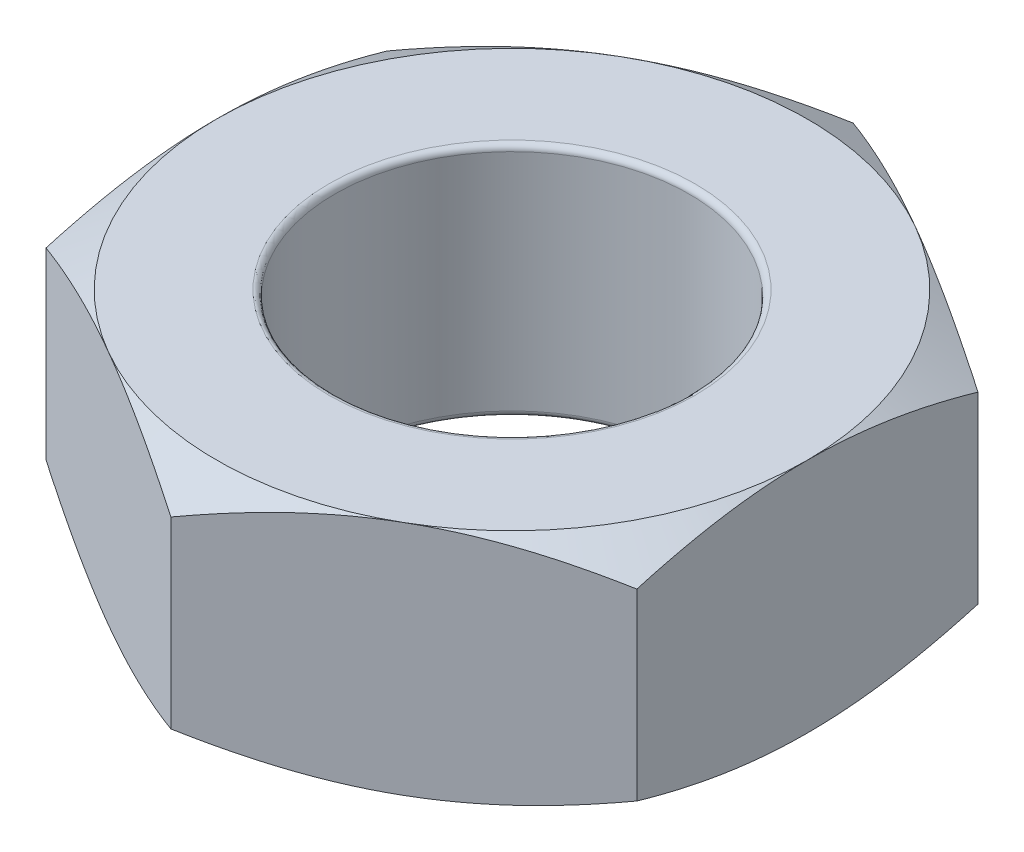
from build123d import *

# Parameters (mm, degrees)
SKETCH2_R           = 1.5
BOSS_EXTRUDE1_DEPTH = 2
SKETCH3_OUTSIDE_W   = 15.508
SKETCH3_OUTSIDE_H   = 16.282
SKETCH3_OUTSIDE_R   = 2.5
CUT_EXTRUDE1_DEPTH  = 2
CUT_EXTRUDE1_TAPER  = 60
SKETCH4_OUTSIDE_W   = 15.508
SKETCH4_OUTSIDE_H   = 16.282
SKETCH4_OUTSIDE_R   = 2.5
CUT_EXTRUDE2_DEPTH  = 2
CUT_EXTRUDE2_TAPER  = 60
FILLET1_R           = 0.05


with BuildPart() as part:
    # Sketch2 → Boss-Extrude1 (new body)
    with BuildSketch(Plane(origin=(0, 0, 0), x_dir=(1, 0, 0), z_dir=(0, 1, 0))):
        Polygon((2.5, -1.443375673), (2.5, 1.443375673), (0, 2.886751346), (-2.5, 1.443375673), (-2.5, -1.443375673), (0, -2.886751346), align=None)
        Circle(SKETCH2_R, mode=Mode.SUBTRACT)
    extrude(amount=BOSS_EXTRUDE1_DEPTH)

    # Sketch3 outside → Cut-Extrude1 (cut)
    with BuildSketch(Plane(origin=(0, 2, 0), x_dir=(1, 0, 0), z_dir=(0, 1, 0))):
        Rectangle(SKETCH3_OUTSIDE_W, SKETCH3_OUTSIDE_H)
        Circle(SKETCH3_OUTSIDE_R, mode=Mode.SUBTRACT)
    extrude(amount=-CUT_EXTRUDE1_DEPTH, taper=CUT_EXTRUDE1_TAPER, mode=Mode.SUBTRACT)

    # Sketch4 outside → Cut-Extrude2 (cut)
    with BuildSketch(Plane.XZ):
        Rectangle(SKETCH4_OUTSIDE_W, SKETCH4_OUTSIDE_H)
        Circle(SKETCH4_OUTSIDE_R, mode=Mode.SUBTRACT)
    extrude(amount=-CUT_EXTRUDE2_DEPTH, taper=CUT_EXTRUDE2_TAPER, mode=Mode.SUBTRACT)

    # Fillet1
    fillet1_edges = [part.edges().sort_by_distance(p)[0] for p in [
        (-1.5, 0, 0),
        (-1.5, 2, 0),
    ]]
    fillet(fillet1_edges, radius=FILLET1_R)


solid = part.part
